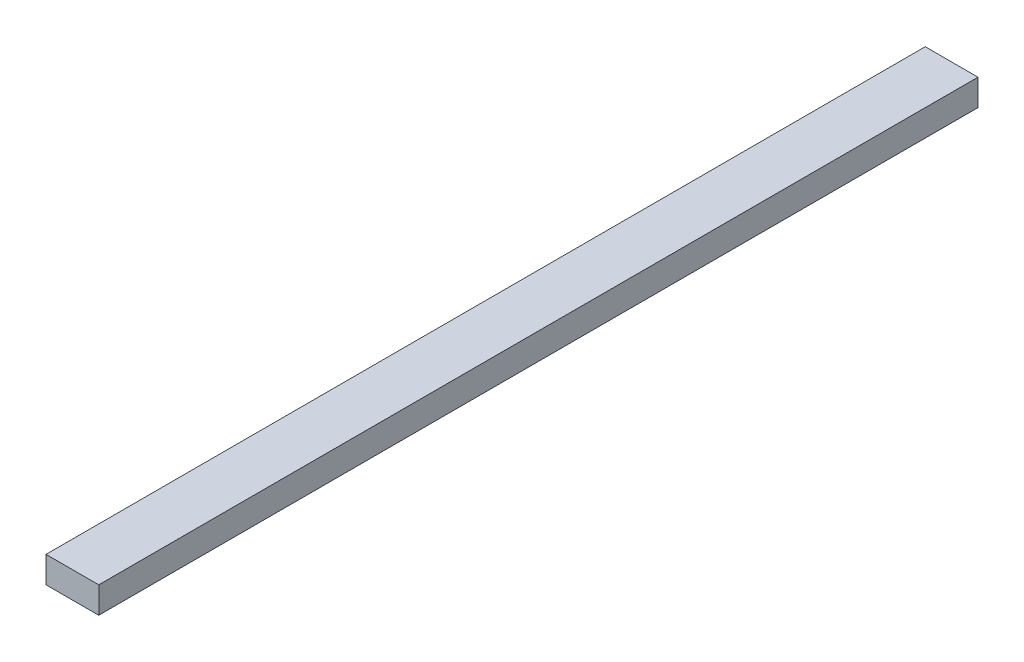
from build123d import *

# Parameters (mm, degrees)
SKETCH1_W           = 30
SKETCH1_H           = 15
BOSS_EXTRUDE1_DEPTH = 500


with BuildPart() as part:
    # Sketch1 → Boss-Extrude1 (new body)
    with BuildSketch(Plane.XY):
        with Locations((5.515752625, -12.14594099)):
            Rectangle(SKETCH1_W, SKETCH1_H)
    extrude(amount=BOSS_EXTRUDE1_DEPTH)


solid = part.part
